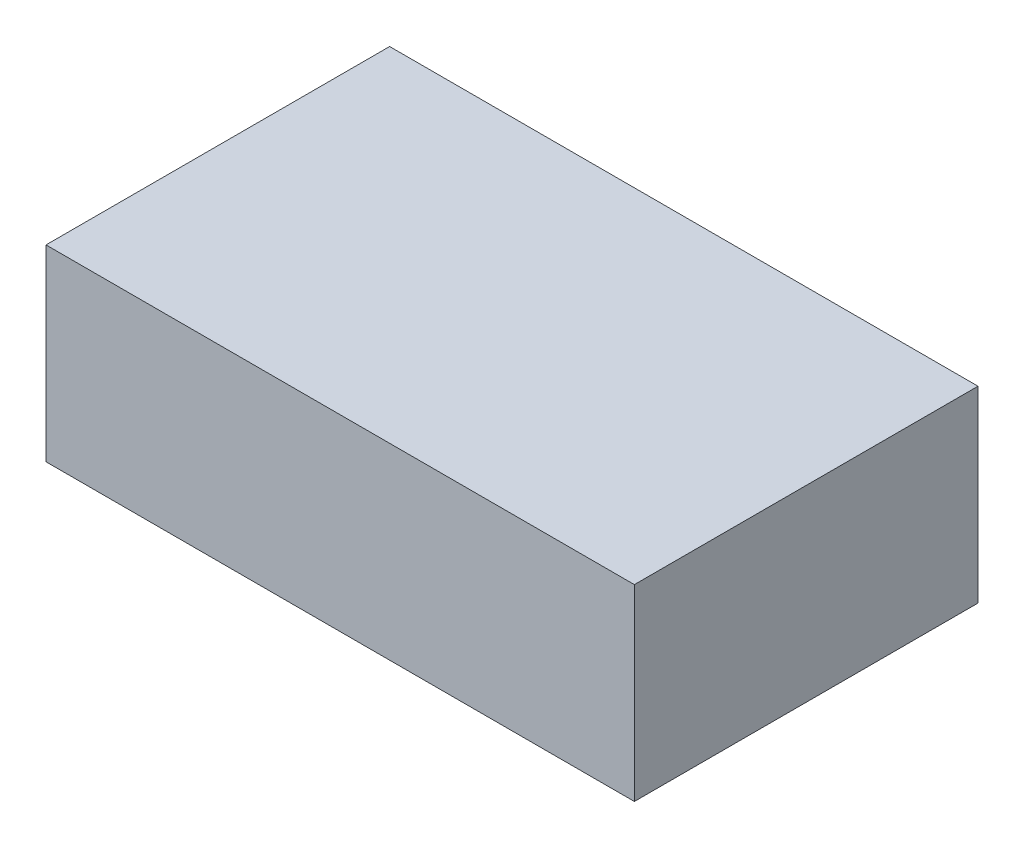
from build123d import *

# Parameters (mm, degrees)
SKETCH1_W           = 106.5
SKETCH1_H           = 62.2
BOSS_EXTRUDE1_DEPTH = 34


with BuildPart() as part:
    # Sketch1 → Boss-Extrude1 (new body)
    with BuildSketch(Plane(origin=(0, 0, 0), x_dir=(1, 0, 0), z_dir=(0, 1, 0))):
        Rectangle(SKETCH1_W, SKETCH1_H)
    extrude(amount=BOSS_EXTRUDE1_DEPTH)


solid = part.part
